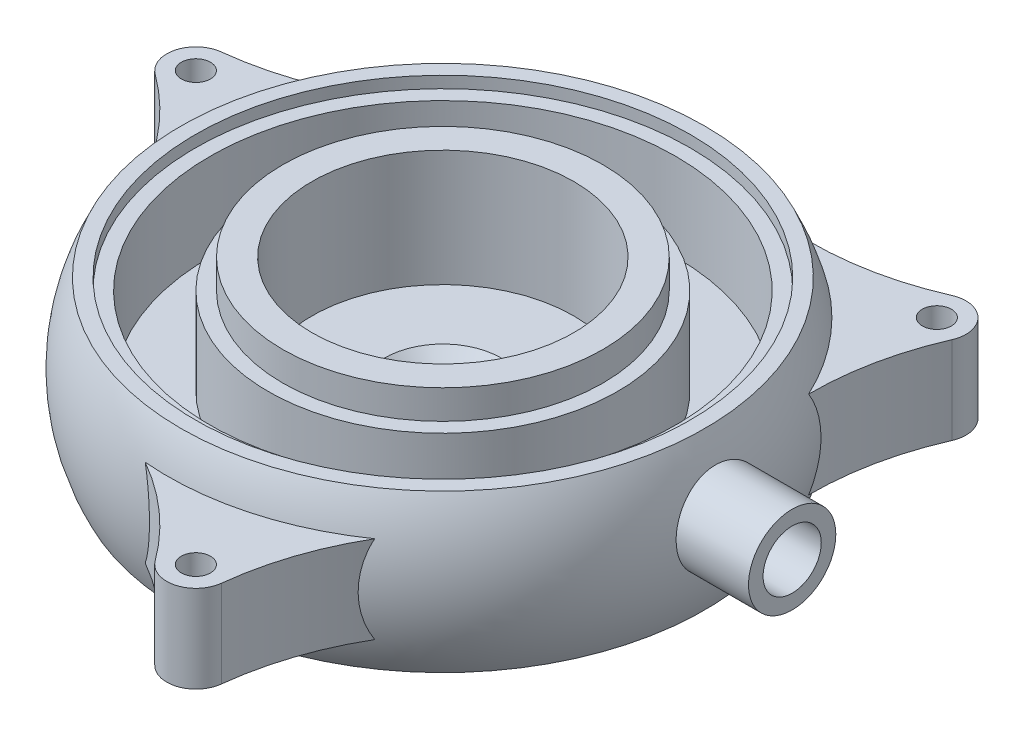
from build123d import *

# Parameters (mm, degrees)
SKETCH2_R                      = 5
BOSS_EXTRUDE2_DEPTH            = 15
CIRPATTERN1_COUNT              = 3
BOSS_EXTRUDE3_REACH            = 247.911
BOSS_EXTRUDE3_END_MAJOR_RADIUS = 36.418286702
BOSS_EXTRUDE3_END_MINOR_RADIUS = 60
SKETCH4_R                      = 15
CUT_EXTRUDE1_REACH             = 247.911
CUT_EXTRUDE1_END_RADIUS        = 80
SKETCH5_R                      = 10


with BuildPart() as part:
    # Sketch1 → Revolve1 (revolve)
    with BuildSketch(Plane.XY, mode=Mode.PRIVATE) as revolve1_sk:
        with BuildLine():
            Line((10, 0), (20, 10))
            Line((20, 10), (45, 10))
            Line((45, 10), (45, 50))
            Line((45, 50), (55, 50))
            Line((55, 50), (55, 40))
            Line((55, 40), (60, 40))
            Line((60, 40), (60, 10))
            Line((60, 10), (80, 10))
            Line((80, 10), (80, 40))
            Line((80, 40), (85, 40))
            Line((85, 40), (85, 44))
            Line((85, 44), (90, 44))
            ThreePointArc((90, 44), (96.418286702, 17), (90, -10))
            Line((90, -10), (85, -10))
            Line((85, -10), (85, 0))
            Line((85, 0), (10, 0))
        make_face()
    revolve(revolve1_sk.sketch.rotate(Axis((0, 0, 0), (0, 1, 0)), 90), axis=Axis((0, 0, 0), (0, 1, 0)))  # turned: the seam where the file's is

    # Sketch2 → Boss-Extrude2 (add, symmetric)
    with BuildSketch(Plane(origin=(0, 17, 0), x_dir=(1, 0, 0), z_dir=(0, 1, 0))):
        with BuildLine():
            ThreePointArc((80.837121698, 94.011100559), (91.923881554, 91.923881554), (94.011100559, 80.837121698))
            ThreePointArc((94.011100559, 80.837121698), (86.080918037, 50.53681039), (87.912932552, 19.269569017))
            ThreePointArc((87.912932552, 19.269569017), (63.639610307, 63.639610307), (19.269569017, 87.912932552))
            ThreePointArc((19.269569017, 87.912932552), (50.53681039, 86.080918037), (80.837121698, 94.011100559))
        make_face()
        with Locations(Location((84.852813742, 84.852813742, 0), (0, 0, 270))):  # turned: the seam where the file's is
            Circle(SKETCH2_R, mode=Mode.SUBTRACT)
    boss_extrude2 = extrude(amount=BOSS_EXTRUDE2_DEPTH, both=True)

    # CirPattern1: Boss-Extrude2 ×3 about axis
    cirpattern1_axis = Axis((0, 0, 0), (0, 1, 0))
    for i in range(1, CIRPATTERN1_COUNT):
        add(boss_extrude2.rotate(cirpattern1_axis, i * 360 / CIRPATTERN1_COUNT))

    # Boss-Extrude3: up to this torus (the profile starts outside it)
    boss_extrude3_end = Plane(origin=(0, 17, 0), z_dir=(0, -1, 0)) * Torus(BOSS_EXTRUDE3_END_MAJOR_RADIUS, BOSS_EXTRUDE3_END_MINOR_RADIUS, mode=Mode.PRIVATE)
    # Sketch4 → Boss-Extrude3 (add, up to the surface)
    with BuildSketch(Plane(origin=(120, 0, 0), x_dir=(0, 0, -1), z_dir=(1, 0, 0)), mode=Mode.PRIVATE) as boss_extrude3_sk1:
        with Locations((0, 20)):
            Circle(SKETCH4_R)
    boss_extrude3_tool1 = extrude(boss_extrude3_sk1.sketch, amount=-BOSS_EXTRUDE3_REACH, mode=Mode.PRIVATE) - boss_extrude3_end
    add(boss_extrude3_tool1.solids().sort_by_distance((120, 20, 0))[0])

    # Cut-Extrude1: up to this cylinder (the profile starts outside it)
    cut_extrude1_end = Plane(origin=(0, 20, 0), z_dir=(0, -1, 0)) * Cylinder(CUT_EXTRUDE1_END_RADIUS, 656.822, mode=Mode.PRIVATE)
    # Sketch5 → Cut-Extrude1 (cut, up to the surface)
    with BuildSketch(Plane(origin=(120, 0, 0), x_dir=(0, 0, -1), z_dir=(1, 0, 0)), mode=Mode.PRIVATE) as cut_extrude1_sk1:
        with Locations((0, 20)):
            Circle(SKETCH5_R)
    cut_extrude1_tool1 = extrude(cut_extrude1_sk1.sketch, amount=-CUT_EXTRUDE1_REACH, mode=Mode.PRIVATE) - cut_extrude1_end
    add(cut_extrude1_tool1.solids().sort_by_distance((120, 20, 0))[0], mode=Mode.SUBTRACT)


solid = part.part
